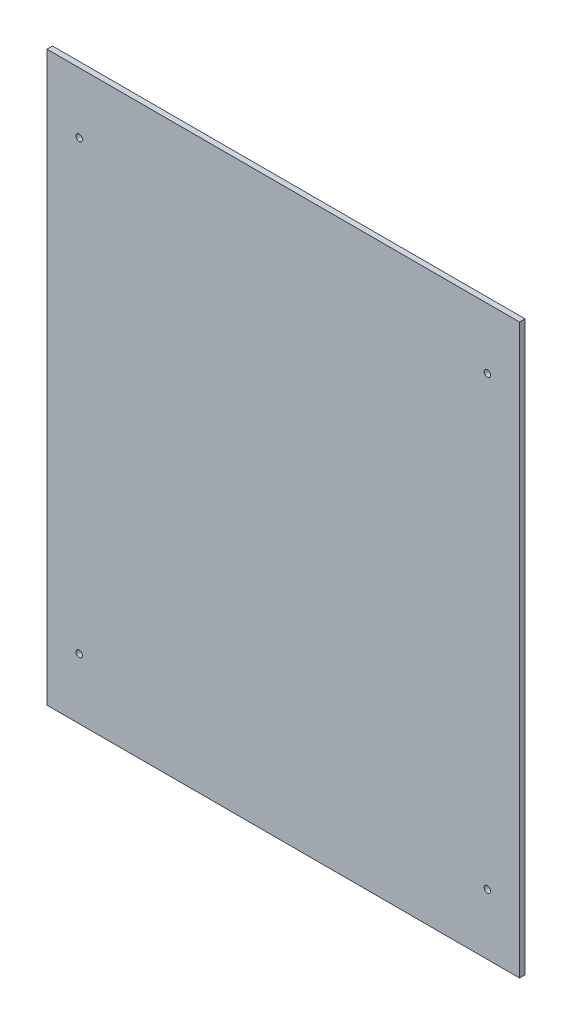
from build123d import *

# Parameters (mm, degrees)
ESQUISSE1_W        = 257
ESQUISSE1_H        = 309
ESQUISSE1_R        = 1.75
BOSS_EXTRU_1_DEPTH = 3


with BuildPart() as part:
    # Esquisse1 → Boss.-Extru.1 (new body)
    with BuildSketch(Plane.XY):
        Rectangle(ESQUISSE1_W, ESQUISSE1_H)
        with Locations((-111, 121.5)):
            Circle(ESQUISSE1_R, mode=Mode.SUBTRACT)
        with Locations((111, 121.5)):
            Circle(ESQUISSE1_R, mode=Mode.SUBTRACT)
        with Locations((111, -121.5)):
            Circle(ESQUISSE1_R, mode=Mode.SUBTRACT)
        with Locations((-111, -121.5)):
            Circle(ESQUISSE1_R, mode=Mode.SUBTRACT)
    extrude(amount=BOSS_EXTRU_1_DEPTH)


solid = part.part
